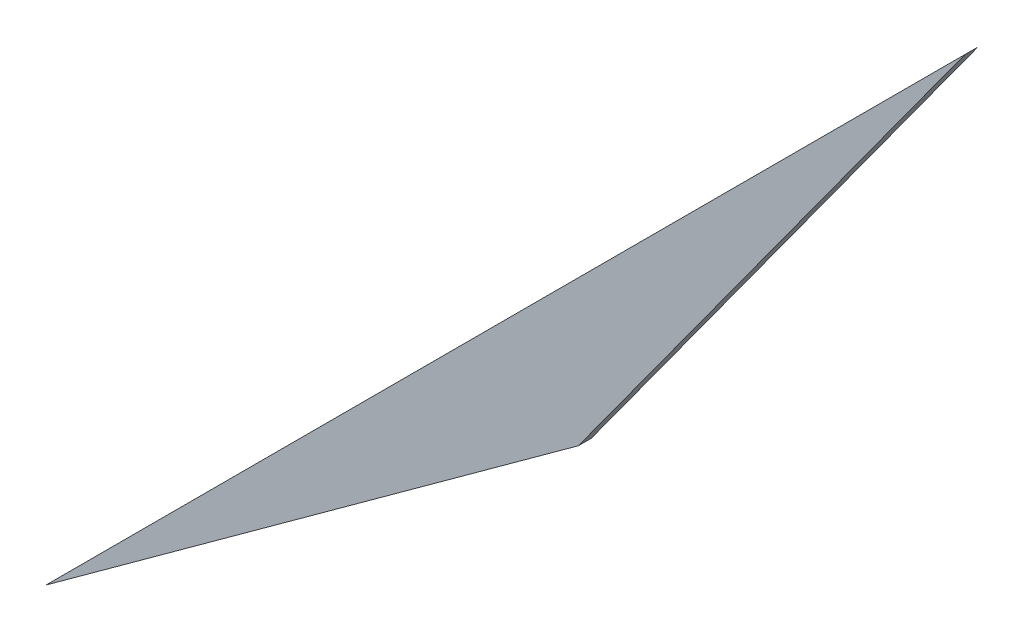
from build123d import *

# Parameters (mm, degrees)
EXTRUDE1_DEPTH = 3.175


with BuildPart() as part:
    # Sketch1 → Extrude1 (new body)
    with BuildSketch(Plane.XY):
        Polygon((-372.576113105, 145.779690358), (-241.217389489, 241.217389489), (-145.779690358, 372.576113105), align=None)
    extrude(amount=EXTRUDE1_DEPTH)


solid = part.part
